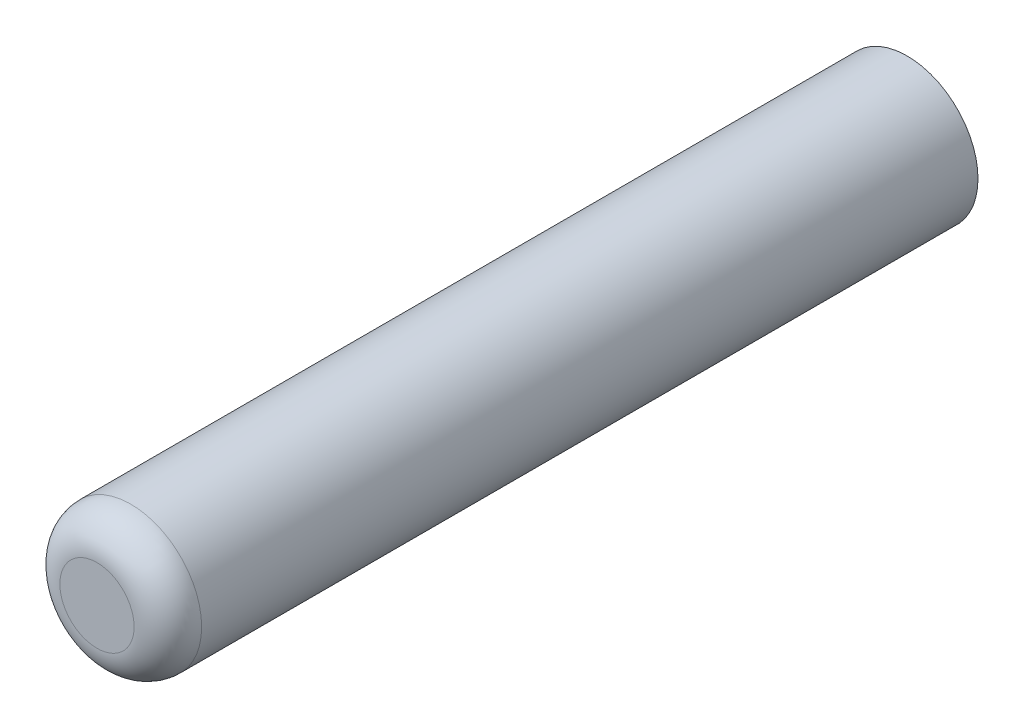
from build123d import *

# Parameters (mm, degrees)
SKETCH1_R           = 1.05
BOSS_EXTRUDE1_DEPTH = 12
FILLET1_R           = 0.5


with BuildPart() as part:
    # Sketch1 → Boss-Extrude1 (new body)
    with BuildSketch(Plane.XY):
        Circle(SKETCH1_R)
    extrude(amount=BOSS_EXTRUDE1_DEPTH)

    # Fillet1
    fillet1_edges = [part.edges().sort_by_distance(p)[0] for p in [
        (-1.05, 0, 12),
    ]]
    fillet(fillet1_edges, radius=FILLET1_R)


solid = part.part
